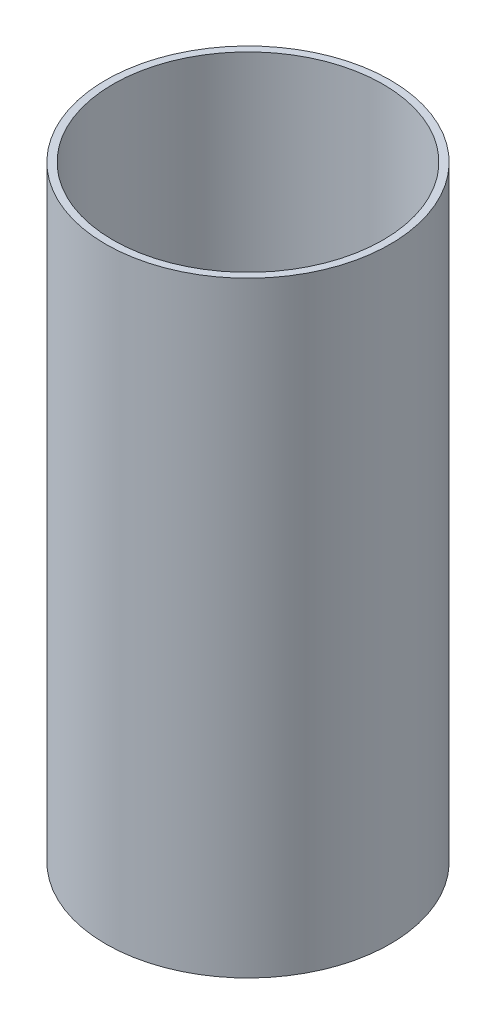
from build123d import *

# Parameters (mm, degrees)
SKETCH1_R           = 93.6625
SKETCH1_R_2         = 88.9
BOSS_EXTRUDE1_DEPTH = 199.517


with BuildPart() as part:
    # Sketch1 → Boss-Extrude1 (new body, symmetric)
    with BuildSketch(Plane(origin=(0, 0, 0), x_dir=(1, 0, 0), z_dir=(0, 1, 0))):
        Circle(SKETCH1_R)
        Circle(SKETCH1_R_2, mode=Mode.SUBTRACT)
    extrude(amount=BOSS_EXTRUDE1_DEPTH, both=True)


solid = part.part
